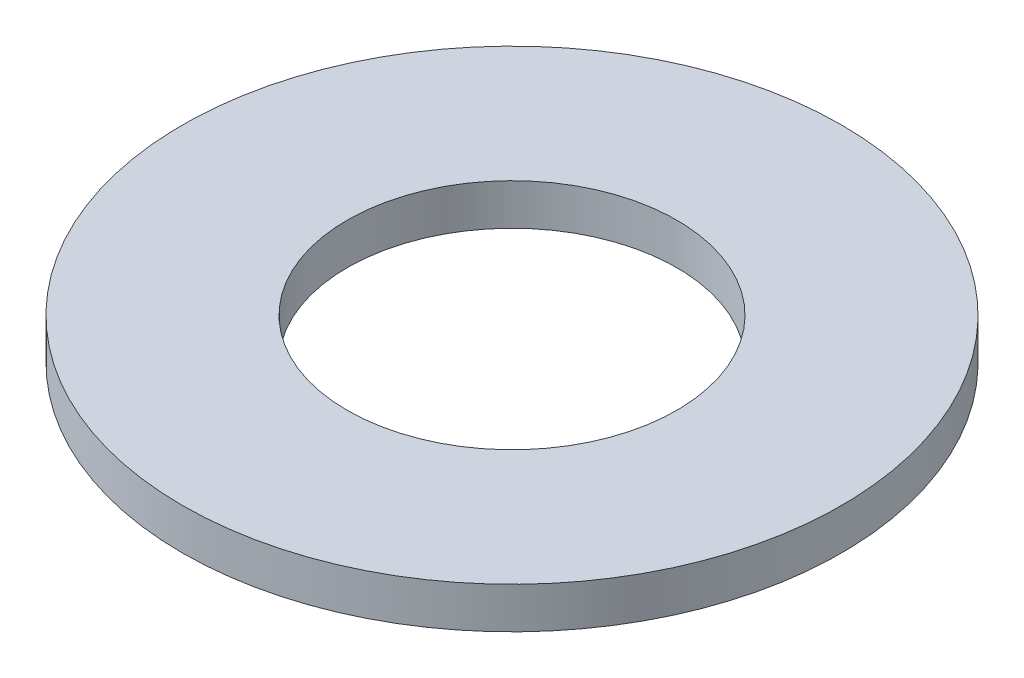
from build123d import *

# Parameters (mm, degrees)
SKETCH1_R           = 6.35
SKETCH1_R_2         = 3.175
BOSS_EXTRUDE1_DEPTH = 0.79375


with BuildPart() as part:
    # Sketch1 → Boss-Extrude1 (new body)
    with BuildSketch(Plane(origin=(0, 0, 0), x_dir=(1, 0, 0), z_dir=(0, 1, 0))):
        Circle(SKETCH1_R)
        Circle(SKETCH1_R_2, mode=Mode.SUBTRACT)
    extrude(amount=BOSS_EXTRUDE1_DEPTH)


solid = part.part
